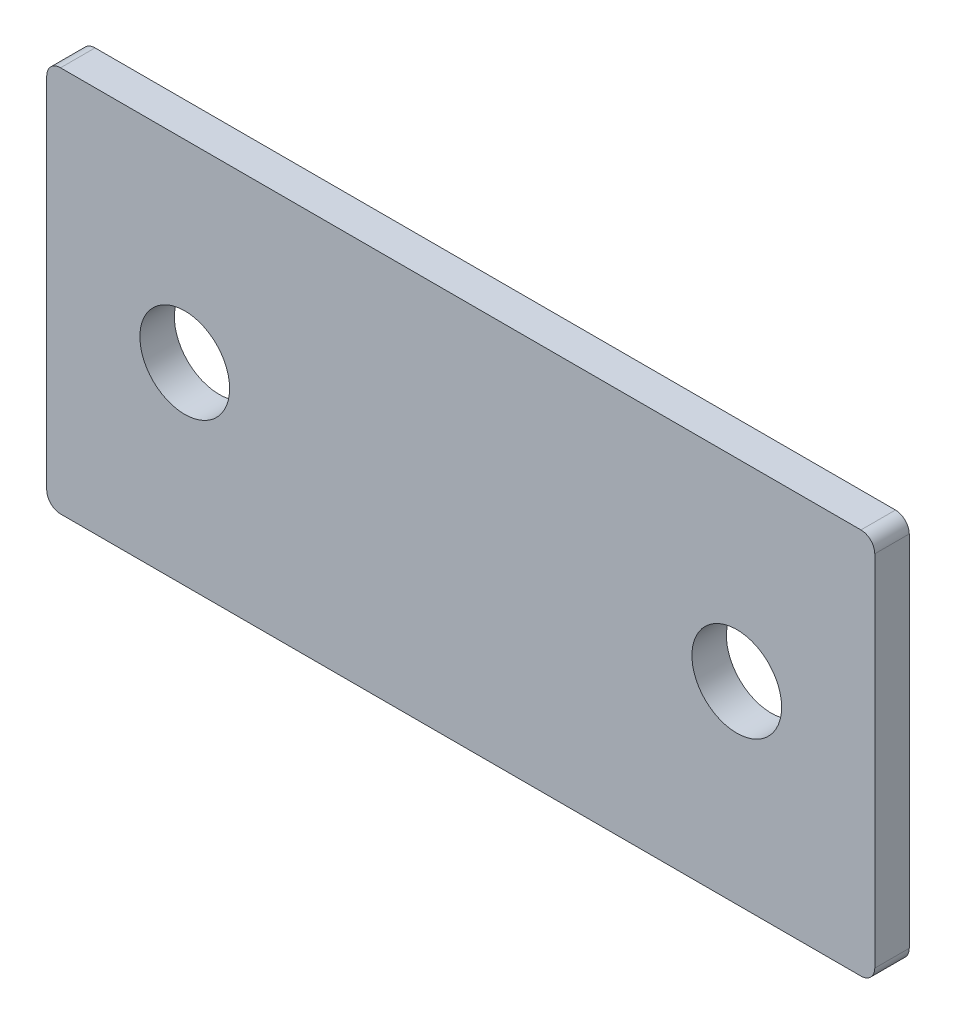
from build123d import *

# Parameters (mm, degrees)
SKETCH_1_W      = 60
SKETCH_1_H      = 28
SKETCH_1_R      = 3.25
EXTRUDE_1_DEPTH = 2.5
FILLET_1_R      = 1


with BuildPart() as part:
    # Эскиз1 → Бобышка-Вытянуть1 (new body)
    with BuildSketch(Plane.XY):
        Rectangle(SKETCH_1_W, SKETCH_1_H)
        with Locations((-20, 0)):
            Circle(SKETCH_1_R, mode=Mode.SUBTRACT)
        with Locations((20, 0)):
            Circle(SKETCH_1_R, mode=Mode.SUBTRACT)
    extrude(amount=EXTRUDE_1_DEPTH)

    # Скругление1
    fillet_1_edges = [part.edges().sort_by_distance(p)[0] for p in [
        (30, -14, 1.25),
        (-30, -14, 1.25),
        (-30, 14, 1.25),
        (30, 14, 1.25),
    ]]
    fillet(fillet_1_edges, radius=FILLET_1_R)


solid = part.part
